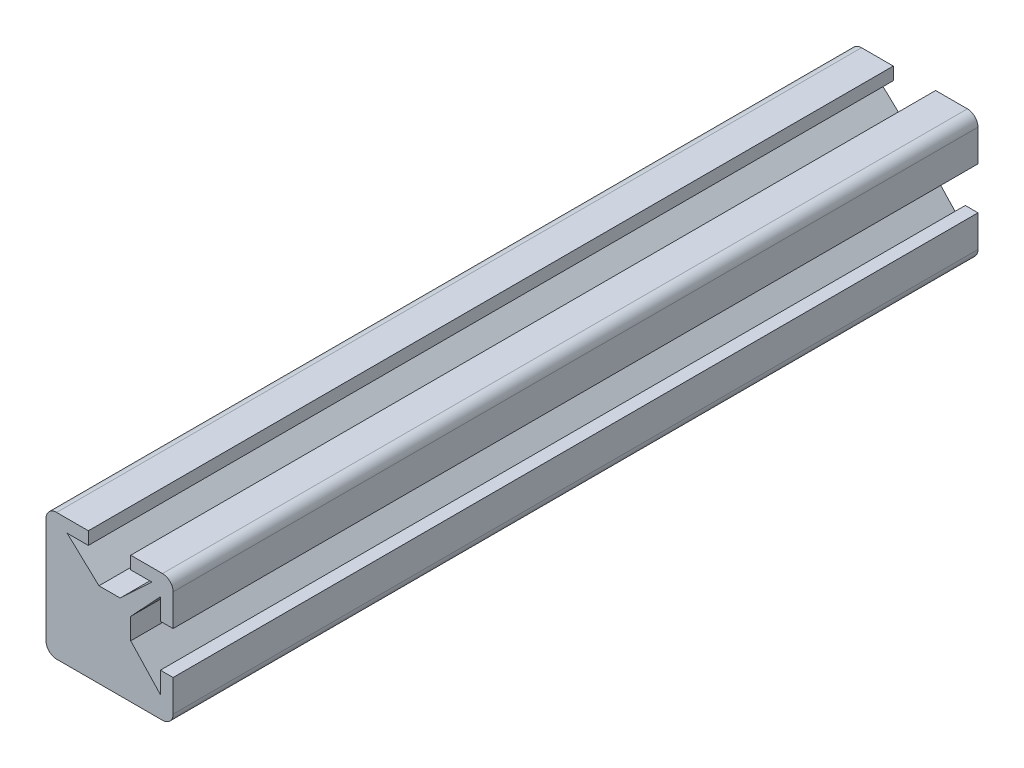
from build123d import *

# Parameters (mm, degrees)
EXTRUSION1_DEPTH             = 38
ENL_V_MAT_EXTRU_1_DEPTH      = 77.472217177
R_P_TITION_CIRCULAIRE1_COUNT = 2
R_P_TITION_CIRCULAIRE1_ANGLE = 90


with BuildPart() as part:
    # Esquisse1 → Extrusion1 (new, symmetric)
    with BuildSketch(Plane.XY):
        with BuildLine():
            Line((-6, 5), (-6, -5))
            ThreePointArc((-6, -5), (-5.707106781, -5.707106781), (-5, -6))
            Line((-5, -6), (5, -6))
            ThreePointArc((5, -6), (5.707106781, -5.707106781), (6, -5))
            Line((6, -5), (6, 5))
            ThreePointArc((6, 5), (5.707106781, 5.707106781), (5, 6))
            Line((5, 6), (-5, 6))
            ThreePointArc((-5, 6), (-5.707106781, 5.707106781), (-6, 5))
        make_face()
    extrude(amount=EXTRUSION1_DEPTH, both=True)

    # Esquisse3 → Enlèv. mat.-Extru.1 (cut, through all)
    with BuildSketch(Plane.XY.offset(38)):
        Polygon((6, 2), (4.8, 2), (4.8, 4), (2, 1), (2, -1), (4.8, -4), (4.8, -2), (6, -2), align=None)
    enl_v_mat_extru_1 = extrude(amount=-ENL_V_MAT_EXTRU_1_DEPTH, mode=Mode.SUBTRACT)

    # Répétition circulaire1: Enlèv. mat.-Extru.1 ×2 about axis
    r_p_tition_circulaire1_axis = Axis((0, 0, -1), (0, 0, 1))
    for i in range(1, R_P_TITION_CIRCULAIRE1_COUNT):
        add(enl_v_mat_extru_1.rotate(r_p_tition_circulaire1_axis, i * R_P_TITION_CIRCULAIRE1_ANGLE / (R_P_TITION_CIRCULAIRE1_COUNT - 1)), mode=Mode.SUBTRACT)


solid = part.part
